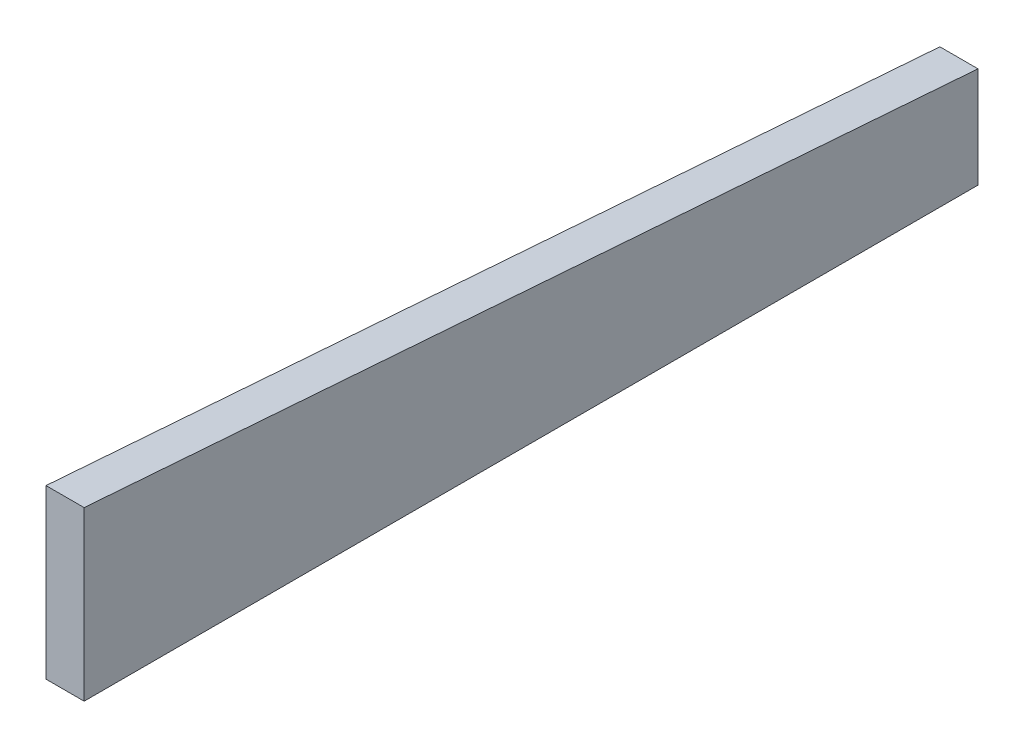
from build123d import *

# Parameters (mm, degrees)
BOSS_EXTRUDE1_DEPTH = 3.5814


with BuildPart() as part:
    # Sketch1 → Boss-Extrude1 (new body)
    with BuildSketch(Plane(origin=(0, 0, 0), x_dir=(0, 0, -1), z_dir=(1, 0, 0))):
        Polygon((0, 0), (83.947, -6.2865), (83.947, -15.748), (0, -15.748), align=None)
    extrude(amount=BOSS_EXTRUDE1_DEPTH)


solid = part.part
